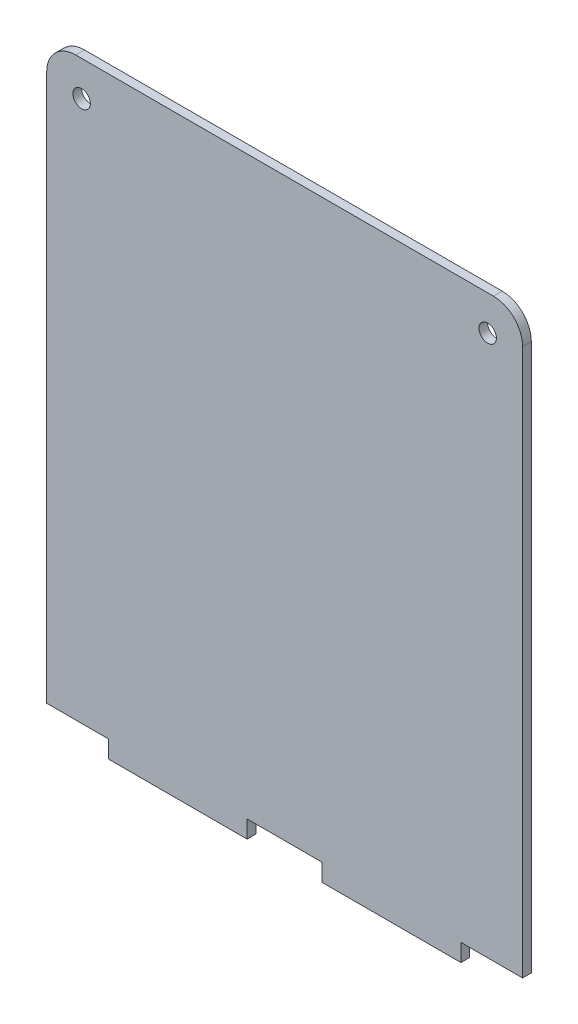
from build123d import *

# Parameters (mm, degrees)
SKETCH1_W           = 81.8
SKETCH1_H           = 102
BOSS_EXTRUDE1_DEPTH = 1.5
SKETCH2_W           = 10.6
SKETCH2_H           = 3
SKETCH2_W_2         = 6.445
SKETCH2_R           = 1.5
CUT_EXTRUDE1_DEPTH  = 2.5
FILLET1_R           = 5


with BuildPart() as part:
    # Sketch1 → Boss-Extrude1 (new body)
    with BuildSketch(Plane.XY):
        with Locations((40.9, 51)):
            Rectangle(SKETCH1_W, SKETCH1_H)
    extrude(amount=BOSS_EXTRUDE1_DEPTH)

    # Sketch2 → Cut-Extrude1 (cut, through all)
    with BuildSketch(Plane.XY.offset(1.5)):
        with Locations((5.3, 1.5)):
            Rectangle(SKETCH2_W, SKETCH2_H)
        with Locations((44.1225, 1.5)):
            Rectangle(SKETCH2_W_2, SKETCH2_H)
        with Locations((37.6775, 1.5)):
            Rectangle(SKETCH2_W_2, SKETCH2_H)
        with Locations((76.5, 1.5)):
            Rectangle(SKETCH2_W, SKETCH2_H)
        with Locations((6, 96)):
            Circle(SKETCH2_R)
        with Locations((75.8, 96)):
            Circle(SKETCH2_R)
    extrude(amount=-CUT_EXTRUDE1_DEPTH, mode=Mode.SUBTRACT)

    # Fillet1
    fillet1_edges = [part.edges().sort_by_distance(p)[0] for p in [
        (0, 102, 0.75),
        (81.8, 102, 0.75),
    ]]
    fillet(fillet1_edges, radius=FILLET1_R)


solid = part.part
